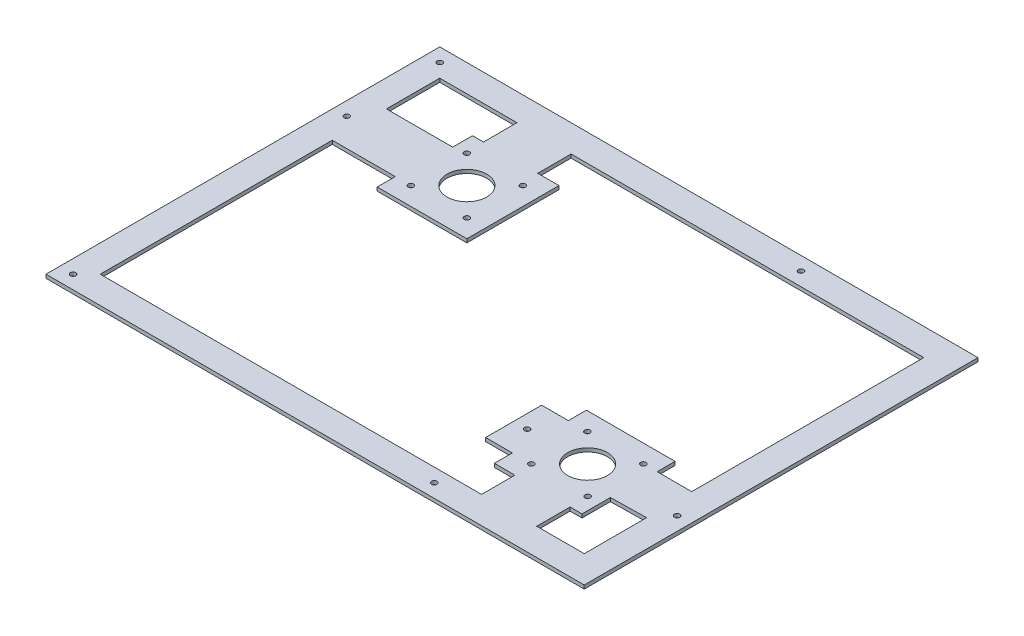
from build123d import *

# Parameters (mm, degrees)
SKETCH1_W           = 218
SKETCH1_H           = 2
BOSS_EXTRUDE1_DEPTH = 298
SKETCH2_R           = 11
SKETCH2_R_2         = 1.5
CUT_EXTRUDE1_DEPTH  = 10


with BuildPart() as part:
    # Sketch1 → Boss-Extrude1 (new body)
    with BuildSketch(Plane(origin=(0, 0, 0), x_dir=(0, 0, -1), z_dir=(1, 0, 0))):
        with Locations((82.3216851, 1)):
            Rectangle(SKETCH1_W, SKETCH1_H)
    extrude(amount=BOSS_EXTRUDE1_DEPTH)

    # Sketch2 → Cut-Extrude1 (cut)
    with BuildSketch(Plane(origin=(0, 2, 0), x_dir=(1, 0, 0), z_dir=(0, 1, 0))):
        with Locations((74, 132.3216851)):
            Circle(SKETCH2_R)
        with Locations((89.5, 116.8216851)):
            Circle(SKETCH2_R_2)
        with Locations((58.5, 116.8216851)):
            Circle(SKETCH2_R_2)
        with Locations((89.5, 147.8216851)):
            Circle(SKETCH2_R_2)
        with Locations((58.5, 147.8216851)):
            Circle(SKETCH2_R_2)
        with Locations((256.33130124, 47.719426297)):
            Circle(SKETCH2_R_2)
        with Locations((256.457517214, 16.719426297)):
            Circle(SKETCH2_R_2)
        with Locations((225.33130124, 16.719426297)):
            Circle(SKETCH2_R_2)
        with Locations((225.33130124, 47.719426297)):
            Circle(SKETCH2_R_2)
        with Locations((240.957517214, 32.219426297)):
            Circle(SKETCH2_R)
        with Locations((290.5, 32.219426297)):
            Circle(SKETCH2_R_2)
        with Locations((7.5, 132.3216851)):
            Circle(SKETCH2_R_2)
        with Locations((207.490401532, 32.219426297)):
            Circle(SKETCH2_R_2)
        with Locations((207.490401532, 183.8216851)):
            Circle(SKETCH2_R_2)
        with Locations((207.490401532, -19.1783149)):
            Circle(SKETCH2_R_2)
        with Locations((7.5, -19.1783149)):
            Circle(SKETCH2_R_2)
        with Locations((7.5, 183.8216851)):
            Circle(SKETCH2_R_2)
        Polygon((15, 176.3216851), (57.721228679, 176.3216851), (57.721228679, 157.8216851), (51.65209525, 157.8216851), (51.65209525, 146.8216851), (15, 146.8216851), (15, 159.517007057), align=None)
        Polygon((149, -11.6783149), (104.471210326, -11.6783149), (15, -11.6783149), (15, 89.941809838), (15, 116.8216851), (49.873323929, 116.8216851), (49.873323929, 106.8216851), (99.5, 106.8216851), (99.5, 157.8216851), (87.721228679, 157.8216851), (87.721228679, 176.3216851), (101.200621078, 176.3216851), (149, 176.3216851), (283, 176.3216851), (283, 47.8216851), (263.876177895, 47.8216851), (263.876177895, 57.719426297), (214.790401532, 57.719426297), (214.790401532, 47.719426297), (199.990401532, 47.719426297), (199.990401532, 16.719426297), (214.790401532, 16.719426297), (214.790401532, 6.77711424), (226.154489119, 6.77711424), (226.154489119, -11.6783149), align=None)
        Polygon((283, -11.6783149), (283, 10.126363143), (283, 22.8216851), (263.305421964, 22.488619524), (263.305421964, 6.7816851), (256.695388827, 6.7816851), (256.695388827, -11.6783149), align=None)
    extrude(amount=-CUT_EXTRUDE1_DEPTH, mode=Mode.SUBTRACT)


solid = part.part
